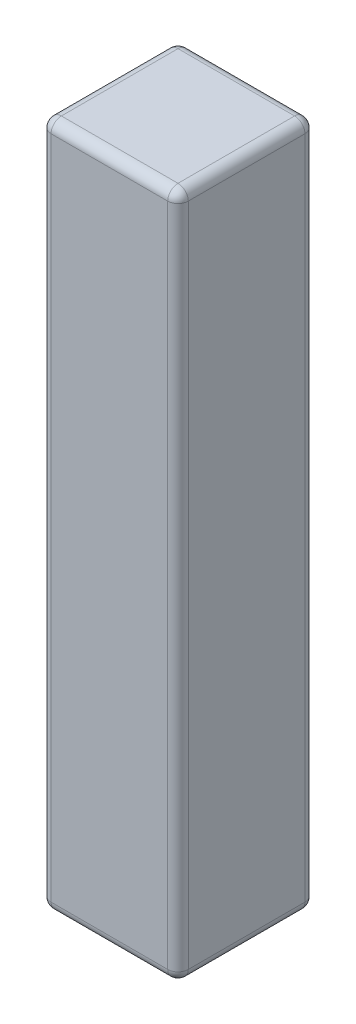
from build123d import *

# Parameters (mm, degrees)
SKETCH1_W      = 2.00000108
SKETCH1_H      = 2.00000108
EXTRUDE2_DEPTH = 5
FILLET2_R      = 0.15


with BuildPart() as part:
    # Sketch1 → Extrude2 (new body, symmetric)
    with BuildSketch(Plane(origin=(0, 0, 0), x_dir=(1, 0, 0), z_dir=(0, 1, 0))):
        Rectangle(SKETCH1_W, SKETCH1_H)
    extrude(amount=EXTRUDE2_DEPTH, both=True)

    # Fillet2
    fillet2_edges = [part.edges().sort_by_distance(p)[0] for p in [
        (1.00000054, 5, 0),
        (0, 5, -1.00000054),
        (-1.00000054, 5, 0),
        (0, -5, -1.00000054),
        (1.00000054, -5, 0),
        (0, -5, 1.00000054),
        (-1.00000054, -5, 0),
        (0, 5, 1.00000054),
        (-1.00000054, 0, -1.00000054),
        (1.00000054, 0, -1.00000054),
        (1.00000054, 0, 1.00000054),
        (-1.00000054, 0, 1.00000054),
    ]]
    fillet(fillet2_edges, radius=FILLET2_R)


solid = part.part
